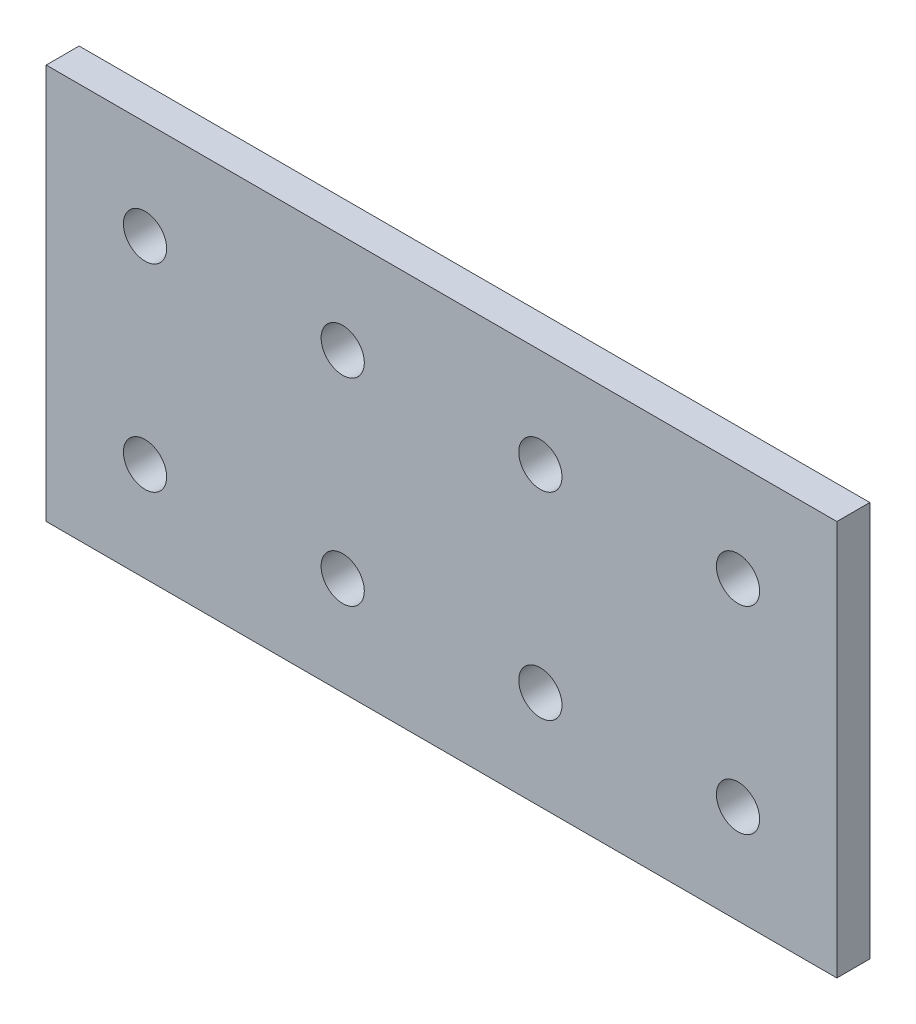
from build123d import *

# Parameters (mm, degrees)
SKETCH1_W           = 152.4
SKETCH1_H           = 76.2
SKETCH1_R           = 4.1656
BOSS_EXTRUDE1_DEPTH = 3.175


with BuildPart() as part:
    # Sketch1 → Boss-Extrude1 (new body, symmetric)
    with BuildSketch(Plane.XY):
        with Locations((76.2, 38.1)):
            Rectangle(SKETCH1_W, SKETCH1_H)
        with Locations((19.05, 19.05)):
            Circle(SKETCH1_R, mode=Mode.SUBTRACT)
        with Locations((57.15, 19.05)):
            Circle(SKETCH1_R, mode=Mode.SUBTRACT)
        with Locations((95.25, 19.05)):
            Circle(SKETCH1_R, mode=Mode.SUBTRACT)
        with Locations((133.35, 19.05)):
            Circle(SKETCH1_R, mode=Mode.SUBTRACT)
        with Locations((19.05, 57.15)):
            Circle(SKETCH1_R, mode=Mode.SUBTRACT)
        with Locations((57.15, 57.15)):
            Circle(SKETCH1_R, mode=Mode.SUBTRACT)
        with Locations((95.25, 57.15)):
            Circle(SKETCH1_R, mode=Mode.SUBTRACT)
        with Locations((133.35, 57.15)):
            Circle(SKETCH1_R, mode=Mode.SUBTRACT)
    extrude(amount=BOSS_EXTRUDE1_DEPTH, both=True)


solid = part.part
